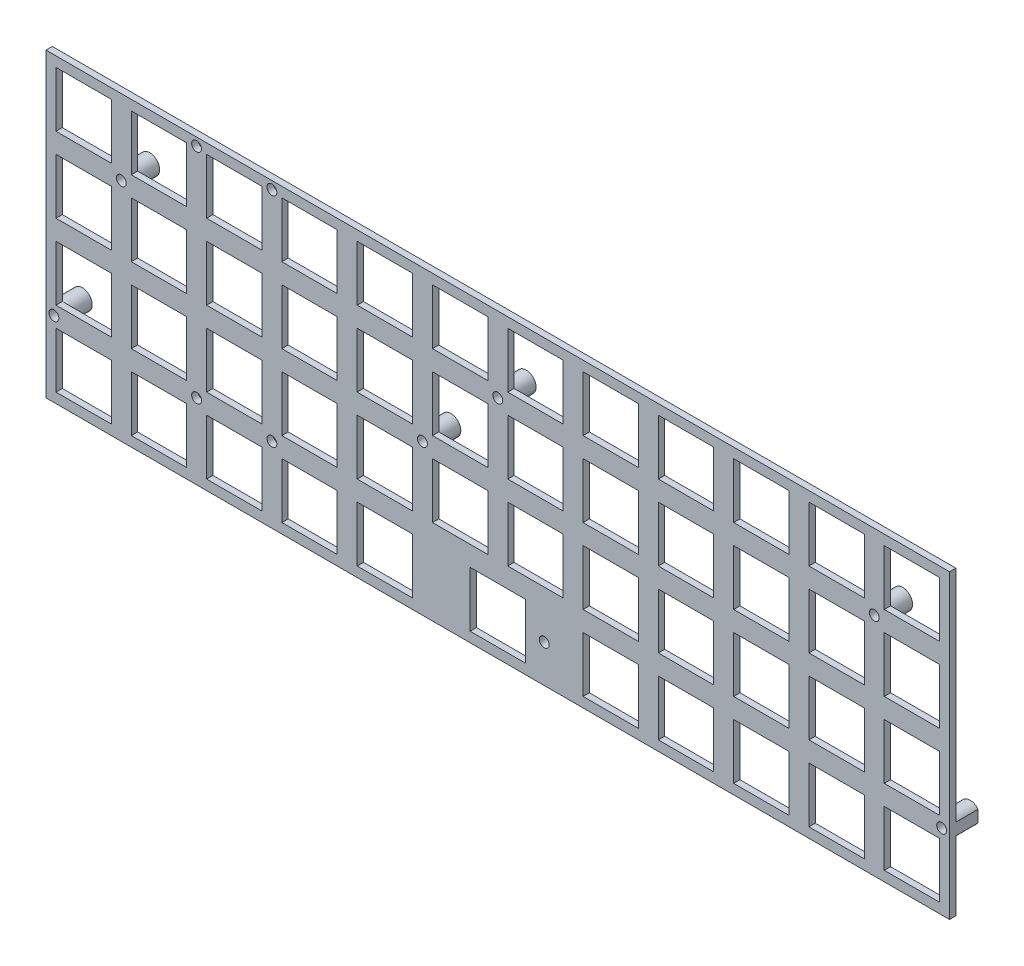
from build123d import *
from build123d.topology import SkipClean

# Parameters (mm, degrees)
CROQUIS1_W                 = 228.6
CROQUIS1_H                 = 76.2
SALIENTE_EXTRUIR1_DEPTH    = 1.6
CROQUIS2_W                 = 14
CROQUIS2_H                 = 14
CORTAR_EXTRUIR1_DEPTH      = 241.970869609
CORTAR_EXTRUIR2_DEPTH      = 241.970869609
CORTAR_EXTRUIR2_DEPTH_BACK = 241.970869609
CROQUIS3_R                 = 1.25
CROQUIS4_R                 = 2.5
CROQUIS4_R_2               = 1.25
SALIENTE_EXTRUIR2_DEPTH    = 5.6
CORTAR_EXTRUIR3_DEPTH      = 242.073100947
CORTAR_EXTRUIR3_DEPTH_BACK = 242.073100947
CROQUIS5_R                 = 1.25


with BuildPart() as part:
    # Croquis1 → Saliente-Extruir1 (new body)
    with BuildSketch(Plane.XY):
        with Locations((114.3, 38.1)):
            Rectangle(CROQUIS1_W, CROQUIS1_H)
    extrude(amount=SALIENTE_EXTRUIR1_DEPTH)

    # Croquis2 → Cortar-Extruir1 (cut, through all)
    with BuildSketch(Plane.XY.offset(1.6)):
        with Locations((28.575, 66.675)):
            Rectangle(CROQUIS2_W, CROQUIS2_H)
        with Locations((9.525, 66.675)):
            Rectangle(CROQUIS2_W, CROQUIS2_H)
        with Locations((47.625, 66.675)):
            Rectangle(CROQUIS2_W, CROQUIS2_H)
        with Locations((66.675, 66.675)):
            Rectangle(CROQUIS2_W, CROQUIS2_H)
        with Locations((85.725, 66.675)):
            Rectangle(CROQUIS2_W, CROQUIS2_H)
        with Locations((104.775, 66.675)):
            Rectangle(CROQUIS2_W, CROQUIS2_H)
        with Locations((123.825, 66.675)):
            Rectangle(CROQUIS2_W, CROQUIS2_H)
        with Locations((142.875, 66.675)):
            Rectangle(CROQUIS2_W, CROQUIS2_H)
        with Locations((161.925, 66.675)):
            Rectangle(CROQUIS2_W, CROQUIS2_H)
        with Locations((180.975, 66.675)):
            Rectangle(CROQUIS2_W, CROQUIS2_H)
        with Locations((200.025, 66.675)):
            Rectangle(CROQUIS2_W, CROQUIS2_H)
        with Locations((219.075, 66.675)):
            Rectangle(CROQUIS2_W, CROQUIS2_H)
        with Locations((28.575, 47.625)):
            Rectangle(CROQUIS2_W, CROQUIS2_H)
        with Locations((47.625, 47.625)):
            Rectangle(CROQUIS2_W, CROQUIS2_H)
        with Locations((66.675, 47.625)):
            Rectangle(CROQUIS2_W, CROQUIS2_H)
        with Locations((85.725, 47.625)):
            Rectangle(CROQUIS2_W, CROQUIS2_H)
        with Locations((104.775, 47.625)):
            Rectangle(CROQUIS2_W, CROQUIS2_H)
        with Locations((123.825, 47.625)):
            Rectangle(CROQUIS2_W, CROQUIS2_H)
        with Locations((142.875, 47.625)):
            Rectangle(CROQUIS2_W, CROQUIS2_H)
        with Locations((161.925, 47.625)):
            Rectangle(CROQUIS2_W, CROQUIS2_H)
        with Locations((180.975, 47.625)):
            Rectangle(CROQUIS2_W, CROQUIS2_H)
        with Locations((200.025, 47.625)):
            Rectangle(CROQUIS2_W, CROQUIS2_H)
        with Locations((219.075, 47.625)):
            Rectangle(CROQUIS2_W, CROQUIS2_H)
        with Locations((28.575, 28.575)):
            Rectangle(CROQUIS2_W, CROQUIS2_H)
        with Locations((47.625, 28.575)):
            Rectangle(CROQUIS2_W, CROQUIS2_H)
        with Locations((66.675, 28.575)):
            Rectangle(CROQUIS2_W, CROQUIS2_H)
        with Locations((85.725, 28.575)):
            Rectangle(CROQUIS2_W, CROQUIS2_H)
        with Locations((104.775, 28.575)):
            Rectangle(CROQUIS2_W, CROQUIS2_H)
        with Locations((123.825, 28.575)):
            Rectangle(CROQUIS2_W, CROQUIS2_H)
        with Locations((142.875, 28.575)):
            Rectangle(CROQUIS2_W, CROQUIS2_H)
        with Locations((161.925, 28.575)):
            Rectangle(CROQUIS2_W, CROQUIS2_H)
        with Locations((180.975, 28.575)):
            Rectangle(CROQUIS2_W, CROQUIS2_H)
        with Locations((200.025, 28.575)):
            Rectangle(CROQUIS2_W, CROQUIS2_H)
        with Locations((219.075, 28.575)):
            Rectangle(CROQUIS2_W, CROQUIS2_H)
        with Locations((28.575, 9.525)):
            Rectangle(CROQUIS2_W, CROQUIS2_H)
        with Locations((47.625, 9.525)):
            Rectangle(CROQUIS2_W, CROQUIS2_H)
        with Locations((66.675, 9.525)):
            Rectangle(CROQUIS2_W, CROQUIS2_H)
        with Locations((85.725, 9.525)):
            Rectangle(CROQUIS2_W, CROQUIS2_H)
        with Locations((142.875, 9.525)):
            Rectangle(CROQUIS2_W, CROQUIS2_H)
        with Locations((161.925, 9.525)):
            Rectangle(CROQUIS2_W, CROQUIS2_H)
        with Locations((180.975, 9.525)):
            Rectangle(CROQUIS2_W, CROQUIS2_H)
        with Locations((200.025, 9.525)):
            Rectangle(CROQUIS2_W, CROQUIS2_H)
        with Locations((219.075, 9.525)):
            Rectangle(CROQUIS2_W, CROQUIS2_H)
        with Locations((9.525, 47.625)):
            Rectangle(CROQUIS2_W, CROQUIS2_H)
        with Locations((9.525, 28.575)):
            Rectangle(CROQUIS2_W, CROQUIS2_H)
        with Locations((9.525, 9.525)):
            Rectangle(CROQUIS2_W, CROQUIS2_H)
        with Locations((114.3, 9.525)):
            Rectangle(CROQUIS2_W, CROQUIS2_H)
    extrude(amount=-CORTAR_EXTRUIR1_DEPTH, mode=Mode.SUBTRACT)

    # Croquis3 → Cortar-Extruir2 (cut, two sides: drawn at the far end of the back side and taken through both)
    with BuildSketch(Plane.XY.offset(1.6).offset(-CORTAR_EXTRUIR2_DEPTH_BACK)):
        with Locations((2, 19.05)):
            Circle(CROQUIS3_R)
        with Locations((226.6, 19.05)):
            Circle(CROQUIS3_R)
        with Locations((126.0625, 9.525)):
            Circle(CROQUIS3_R)
        with Locations((95.25, 38.1)):
            Circle(CROQUIS3_R)
        with Locations((209.55, 57.15)):
            Circle(CROQUIS3_R)
        with Locations((19.05, 57.15)):
            Circle(CROQUIS3_R)
        with Locations((114.3, 57.15)):
            Circle(CROQUIS3_R)
    extrude(amount=CORTAR_EXTRUIR2_DEPTH + CORTAR_EXTRUIR2_DEPTH_BACK, mode=Mode.SUBTRACT)

    # Croquis4 → Saliente-Extruir2 (add)
    # profile 1 of 7: a face of its own
    with SkipClean():  # the faces are left unmerged after this step: merging them gives an invalid solid
        with BuildSketch(Plane(origin=(0, 0, 0), x_dir=(-1, 0, 0), z_dir=(0, 0, -1))):
            with Locations((-209.55, 57.15)):
                Circle(CROQUIS4_R)
            with Locations((-209.55, 57.15)):
                Circle(CROQUIS4_R_2, mode=Mode.SUBTRACT)
        # profile 2 of 7: a face of its own
        with BuildSketch(Plane(origin=(0, 0, 0), x_dir=(-1, 0, 0), z_dir=(0, 0, -1))):
            with Locations((-126.0625, 9.525)):
                Circle(CROQUIS4_R)
            with Locations((-126.0625, 9.525)):
                Circle(CROQUIS4_R_2, mode=Mode.SUBTRACT)
        # profile 3 of 7: a face of its own
        with BuildSketch(Plane(origin=(0, 0, 0), x_dir=(-1, 0, 0), z_dir=(0, 0, -1))):
            with Locations((-95.25, 38.1)):
                Circle(CROQUIS4_R)
            with Locations((-95.25, 38.1)):
                Circle(CROQUIS4_R_2, mode=Mode.SUBTRACT)
        # profile 4 of 7: a face of its own
        with BuildSketch(Plane(origin=(0, 0, 0), x_dir=(-1, 0, 0), z_dir=(0, 0, -1))):
            with Locations((-19.05, 57.15)):
                Circle(CROQUIS4_R)
            with Locations((-19.05, 57.15)):
                Circle(CROQUIS4_R_2, mode=Mode.SUBTRACT)
        # profile 5 of 7: a face of its own
        with BuildSketch(Plane(origin=(0, 0, 0), x_dir=(-1, 0, 0), z_dir=(0, 0, -1))):
            with Locations((-114.3, 57.15)):
                Circle(CROQUIS4_R)
            with Locations((-114.3, 57.15)):
                Circle(CROQUIS4_R_2, mode=Mode.SUBTRACT)
        # profile 6 of 7: a face of its own
        with BuildSketch(Plane(origin=(0, 0, 0), x_dir=(-1, 0, 0), z_dir=(0, 0, -1))):
            with BuildLine():
                Line((-228.6, 17.55), (-228.6, 20.55))
                ThreePointArc((-228.6, 20.55), (-224.1, 19.05), (-228.6, 17.55))
            make_face()
            with Locations((-226.6, 19.05)):
                Circle(CROQUIS4_R_2, mode=Mode.SUBTRACT)
        # profile 7 of 7: a face of its own
        with BuildSketch(Plane(origin=(0, 0, 0), x_dir=(-1, 0, 0), z_dir=(0, 0, -1))):
            with BuildLine():
                Line((0, 17.55), (0, 20.55))
                ThreePointArc((0, 20.55), (-4.5, 19.05), (0, 17.55))
            make_face()
            with Locations((-2, 19.05)):
                Circle(CROQUIS4_R_2, mode=Mode.SUBTRACT)
        extrude(amount=SALIENTE_EXTRUIR2_DEPTH)

    # Croquis5 → Cortar-Extruir3 (cut, two sides: drawn at the far end of the back side and taken through both)
    with SkipClean():  # the faces are left unmerged after this step: merging them gives an invalid solid
        with BuildSketch(Plane.XY.offset(1.6).offset(-CORTAR_EXTRUIR3_DEPTH_BACK)):
            with Locations(Location((38.1, 19.05, 0), (0, 0, 180))):
                Circle(CROQUIS5_R)
            with Locations(Location((57.15, 19.05, 0), (0, 0, 180))):
                Circle(CROQUIS5_R)
            with Locations(Location((38.1, 74.2, 0), (0, 0, 180))):
                Circle(CROQUIS5_R)
            with Locations(Location((57.15, 74.2, 0), (0, 0, 180))):
                Circle(CROQUIS5_R)
        extrude(amount=CORTAR_EXTRUIR3_DEPTH + CORTAR_EXTRUIR3_DEPTH_BACK, mode=Mode.SUBTRACT)


solid = part.part
